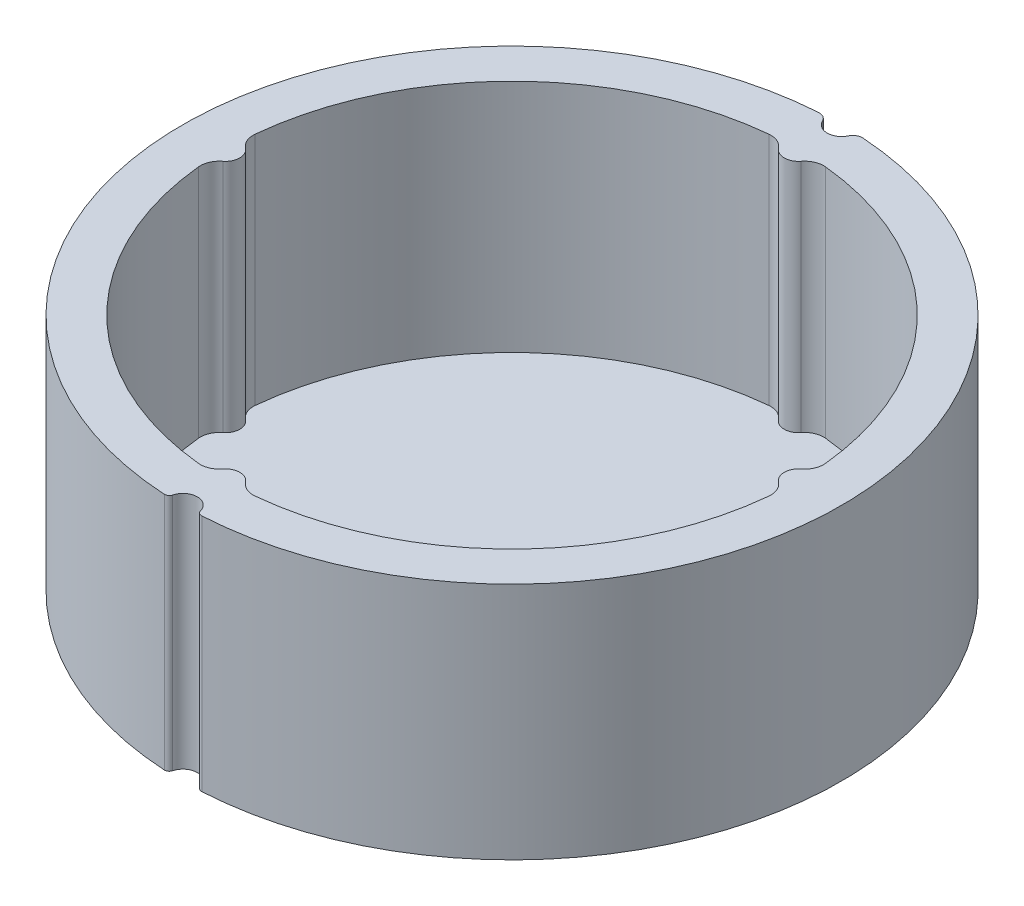
from build123d import *

# Parameters (mm, degrees)
BOSS_EXTRUDE1_DEPTH = 25
CUT_EXTRUDE2_DEPTH  = 55.786493398
BOSS_EXTRUDE2_DEPTH = 0.4


with BuildPart() as part:
    # Sketch1 → Boss-Extrude1 (new body)
    with BuildSketch(Plane(origin=(0, 0, 0), x_dir=(1, 0, 0), z_dir=(0, 1, 0))):
        with BuildLine():
            ThreePointArc((1.451818925, -34.068556857), (1.641248992, -34.346908706), (1.964225605, -34.442038138))
            ThreePointArc((1.964225605, -34.442038138), (26.591847487, -21.978073076), (34.198225299, 4.555174015))
            ThreePointArc((34.198225299, 4.555174015), (23.590291339, 25.176355888), (2.324135821, 34.423627607))
            ThreePointArc((2.324135821, 34.423627607), (1.751838249, 34.289058819), (1.354061739, 33.856153382))
            ThreePointArc((1.354061739, 33.856153382), (0, 33.001534515), (-1.354061739, 33.856153382))
            ThreePointArc((-1.354061739, 33.856153382), (-1.751838249, 34.289058819), (-2.324135821, 34.423627607))
            ThreePointArc((-2.324135821, 34.423627607), (-23.590291339, 25.176355888), (-34.198225299, 4.555174015))
            ThreePointArc((-34.198225299, 4.555174015), (-26.591847487, -21.978073076), (-1.964225605, -34.442038138))
            ThreePointArc((-1.964225605, -34.442038138), (-1.641248992, -34.346908706), (-1.451818925, -34.068556857))
            ThreePointArc((-1.451818925, -34.068556857), (0, -32.945679925), (1.451818925, -34.068556857))
        make_face()
        with BuildLine():
            Line((-2.417, 3.787737139), (0, 3.787737139))
            Line((0, 3.787737139), (2.417, 3.787737139))
            ThreePointArc((2.417, 3.787737139), (0, -4.489512172), (-2.417, 3.787737139))
        make_face(mode=Mode.SUBTRACT)
    extrude(amount=BOSS_EXTRUDE1_DEPTH)

    # Sketch2 → Cut-Extrude2 (cut, through all)
    with BuildSketch(Plane(origin=(0, 0, 0), x_dir=(1, 0, 0), z_dir=(0, 1, 0))):
        with BuildLine():
            ThreePointArc((-29.852678571, -2.96944138), (-21.213203436, -21.213203436), (-2.96944138, -29.852678571))
            ThreePointArc((-2.96944138, -29.852678571), (-1.979132422, -29.698851682), (-1.187776552, -29.083928571))
            ThreePointArc((-1.187776552, -29.083928571), (0, -28.5), (1.187776552, -29.083928571))
            ThreePointArc((1.187776552, -29.083928571), (1.979132422, -29.698851682), (2.96944138, -29.852678571))
            ThreePointArc((2.96944138, -29.852678571), (21.213203436, -21.213203436), (29.852678571, -2.96944138))
            ThreePointArc((29.852678571, -2.96944138), (29.698851682, -1.979132422), (29.083928571, -1.187776552))
            ThreePointArc((29.083928571, -1.187776552), (28.5, 0), (29.083928571, 1.187776552))
            ThreePointArc((29.083928571, 1.187776552), (29.698851682, 1.979132422), (29.852678571, 2.96944138))
            ThreePointArc((29.852678571, 2.96944138), (21.213203436, 21.213203436), (2.96944138, 29.852678571))
            ThreePointArc((2.96944138, 29.852678571), (1.979132422, 29.698851682), (1.187776552, 29.083928571))
            ThreePointArc((1.187776552, 29.083928571), (0, 28.5), (-1.187776552, 29.083928571))
            ThreePointArc((-1.187776552, 29.083928571), (-1.979132422, 29.698851682), (-2.96944138, 29.852678571))
            ThreePointArc((-2.96944138, 29.852678571), (-21.213203436, 21.213203436), (-29.852678571, 2.96944138))
            ThreePointArc((-29.852678571, 2.96944138), (-29.698851682, 1.979132422), (-29.083928571, 1.187776552))
            ThreePointArc((-29.083928571, 1.187776552), (-28.5, 0), (-29.083928571, -1.187776552))
            ThreePointArc((-29.083928571, -1.187776552), (-29.698851682, -1.979132422), (-29.852678571, -2.96944138))
        make_face()
    extrude(amount=CUT_EXTRUDE2_DEPTH, mode=Mode.SUBTRACT)

    # Sketch2_2 → Boss-Extrude2 (add)
    with BuildSketch(Plane(origin=(0, 0, 0), x_dir=(1, 0, 0), z_dir=(0, 1, 0))):
        with BuildLine():
            ThreePointArc((-29.852678571, -2.96944138), (-21.213203436, -21.213203436), (-2.96944138, -29.852678571))
            ThreePointArc((-2.96944138, -29.852678571), (-1.979132422, -29.698851682), (-1.187776552, -29.083928571))
            ThreePointArc((-1.187776552, -29.083928571), (0, -28.5), (1.187776552, -29.083928571))
            ThreePointArc((1.187776552, -29.083928571), (1.979132422, -29.698851682), (2.96944138, -29.852678571))
            ThreePointArc((2.96944138, -29.852678571), (21.213203436, -21.213203436), (29.852678571, -2.96944138))
            ThreePointArc((29.852678571, -2.96944138), (29.698851682, -1.979132422), (29.083928571, -1.187776552))
            ThreePointArc((29.083928571, -1.187776552), (28.5, 0), (29.083928571, 1.187776552))
            ThreePointArc((29.083928571, 1.187776552), (29.698851682, 1.979132422), (29.852678571, 2.96944138))
            ThreePointArc((29.852678571, 2.96944138), (21.213203436, 21.213203436), (2.96944138, 29.852678571))
            ThreePointArc((2.96944138, 29.852678571), (1.979132422, 29.698851682), (1.187776552, 29.083928571))
            ThreePointArc((1.187776552, 29.083928571), (0, 28.5), (-1.187776552, 29.083928571))
            ThreePointArc((-1.187776552, 29.083928571), (-1.979132422, 29.698851682), (-2.96944138, 29.852678571))
            ThreePointArc((-2.96944138, 29.852678571), (-21.213203436, 21.213203436), (-29.852678571, 2.96944138))
            ThreePointArc((-29.852678571, 2.96944138), (-29.698851682, 1.979132422), (-29.083928571, 1.187776552))
            ThreePointArc((-29.083928571, 1.187776552), (-28.5, 0), (-29.083928571, -1.187776552))
            ThreePointArc((-29.083928571, -1.187776552), (-29.698851682, -1.979132422), (-29.852678571, -2.96944138))
        make_face()
    extrude(amount=BOSS_EXTRUDE2_DEPTH)


solid = part.part
